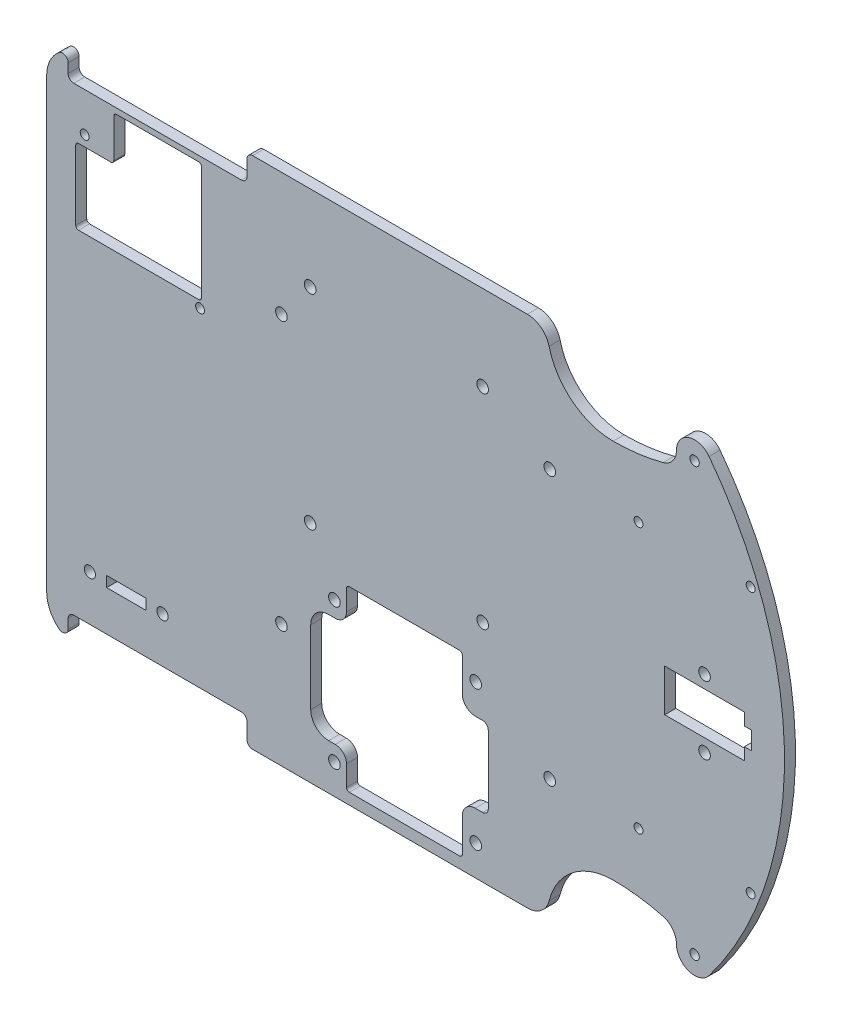
from build123d import *

# Parameters (mm, degrees)
CROQUIS1_W                = 209.55
CROQUIS1_H                = 146.05
SALIENTE_EXTRUIR1_DEPTH   = 3.1242
CROQUIS2_R                = 1.3335
CORTAR_EXTRUIR1_DEPTH     = 128.750584639
CROQUIS9_R                = 1.27
CORTAR_EXTRUIR6_DEPTH     = 128.750584639
CORTAR_EXTRUIR2_DEPTH     = 128.750584639
CROQUIS5_R                = 1.651
DRIVER_DEPTH              = 128.750584639
CROQUIS6_R                = 1.651
RASPI_DEPTH               = 128.750584639
CROQUIS8_R                = 1.27
DIFERENCIAL_TRASERO_DEPTH = 128.750584639
CROQUIS7_R                = 1.5875
CROQUIS7_W                = 11.1125
CROQUIS7_H                = 2.9972
CORTAR_EXTRUIR7_DEPTH     = 128.750584639
CROQUIS10_R               = 1.651
CROQUIS10_W               = 22.606
CROQUIS10_H               = 11.9888
CORTAR_EXTRUIR10_DEPTH    = 128.750584639
CORTAR_EXTRUIR11_DEPTH    = 128.750584639
CROQUIS12_R               = 1.651
CORTAR_EXTRUIR12_DEPTH    = 128.750584639


with BuildPart() as part:
    # Croquis1 → Saliente-Extruir1 (new body)
    with BuildSketch(Plane.XY):
        Rectangle(CROQUIS1_W, CROQUIS1_H)
    extrude(amount=SALIENTE_EXTRUIR1_DEPTH)

    # Croquis2 → Cortar-Extruir1 (cut, through all)
    with BuildSketch(Plane.XY.offset(3.1242)):
        with BuildLine():
            ThreePointArc((80.5799125, 60.7314), (79.928852882, 61.877042778), (78.6114125, 61.904002767))
            Line((78.6114125, 61.904002767), (78.6114125, 59.558797233))
            ThreePointArc((78.6114125, 59.558797233), (79.928852882, 59.585757222), (80.5799125, 60.7314))
        make_face()
        with BuildLine():
            Line((78.6114125, 59.558797233), (78.6114125, 61.904002767))
            ThreePointArc((78.6114125, 61.904002767), (77.9129125, 60.7314), (78.6114125, 59.558797233))
        make_face()
        with Locations(Location((79.2464125, -60.7314, 0), (0, 0, 180))):
            Circle(CROQUIS2_R)
    extrude(amount=-CORTAR_EXTRUIR1_DEPTH, mode=Mode.SUBTRACT)

    # Croquis9 → Cortar-Extruir6 (cut, through all)
    with BuildSketch(Plane.XY.offset(3.1242)):
        with Locations((63.3206125, 37.6809)):
            Circle(CROQUIS9_R)
        with Locations((95.1722125, 37.6809)):
            Circle(CROQUIS9_R)
        with Locations(Location((95.1722125, -37.6809, 0), (0, 0, 180))):
            Circle(CROQUIS9_R)
        with Locations(Location((63.3206125, -37.6809, 0), (0, 0, 180))):
            Circle(CROQUIS9_R)
    extrude(amount=-CORTAR_EXTRUIR6_DEPTH, mode=Mode.SUBTRACT)

    # Croquis3 → Cortar-Extruir2 (cut, through all)
    with BuildSketch(Plane.XY.offset(3.1242)):
        with BuildLine():
            Line((38.1, 67.507041999), (38.1, 73.025))
            Line((38.1, 73.025), (31.75, 73.025))
            ThreePointArc((31.75, 73.025), (35.663372801, 71.675801268), (37.913779422, 68.201539629))
            ThreePointArc((37.913779422, 68.201539629), (38.003556568, 67.853397075), (38.1, 67.507041999))
        make_face()
        with BuildLine():
            Line((74.0870375, 73.025), (38.1, 73.025))
            Line((38.1, 73.025), (38.1, 67.507041999))
            ThreePointArc((38.1, 67.507041999), (44.836488972, 57.735545708), (56.09351875, 53.975))
            ThreePointArc((56.09351875, 53.975), (63.258442282, 54.43812298), (70.304123502, 55.81978439))
            ThreePointArc((70.304123502, 55.81978439), (73.03168636, 57.631625564), (74.0870375, 60.7314))
            Line((74.0870375, 60.7314), (74.0870375, 73.025))
        make_face()
        with BuildLine():
            Line((104.775, 73.025), (74.0870375, 73.025))
            Line((74.0870375, 73.025), (74.0870375, 60.7314))
            ThreePointArc((74.0870375, 60.7314), (77.605786537, 65.622974066), (83.362384549, 63.842336271))
            ThreePointArc((83.362384549, 63.842336271), (99.279214777, 33.668769191), (104.775, 5.82e-07))
            Line((104.775, 5.82e-07), (104.775, 73.025))
        make_face()
        with BuildLine():
            Line((104.775, -73.025), (104.775, 5.82e-07))
            ThreePointArc((104.775, 5.82e-07), (99.279214962, -33.668768639), (83.362384549, -63.842336271))
            ThreePointArc((83.362384549, -63.842336271), (77.605786537, -65.622974066), (74.0870375, -60.7314))
            Line((74.0870375, -60.7314), (74.0870375, -73.025))
            Line((74.0870375, -73.025), (104.775, -73.025))
        make_face()
        with BuildLine():
            Line((74.0870375, -73.025), (74.0870375, -60.7314))
            ThreePointArc((74.0870375, -60.7314), (73.03168636, -57.631625564), (70.304123502, -55.81978439))
            ThreePointArc((70.304123502, -55.81978439), (63.258442282, -54.43812298), (56.09351875, -53.975))
            ThreePointArc((56.09351875, -53.975), (44.836488972, -57.735545708), (38.1, -67.507041999))
            Line((38.1, -67.507041999), (38.1, -73.025))
            Line((38.1, -73.025), (74.0870375, -73.025))
        make_face()
        with BuildLine():
            ThreePointArc((37.913779422, -68.201539629), (35.663372801, -71.675801268), (31.75, -73.025))
            Line((31.75, -73.025), (38.1, -73.025))
            Line((38.1, -73.025), (38.1, -67.507041999))
            ThreePointArc((38.1, -67.507041999), (38.003556568, -67.853397075), (37.913779422, -68.201539629))
        make_face()
        with BuildLine():
            ThreePointArc((-104.775, 63.5), (-101.985192091, 70.235192091), (-95.25, 73.025))
            Line((-95.25, 73.025), (-104.775, 73.025))
            Line((-104.775, 73.025), (-104.775, 63.5))
        make_face()
        with BuildLine():
            Line((-104.775, -73.025), (-95.25, -73.025))
            ThreePointArc((-95.25, -73.025), (-101.985192091, -70.235192091), (-104.775, -63.5))
            Line((-104.775, -63.5), (-104.775, -73.025))
        make_face()
    extrude(amount=-CORTAR_EXTRUIR2_DEPTH, mode=Mode.SUBTRACT)

    # Croquis5 → Driver (cut, through all)
    with BuildSketch(Plane.XY.offset(3.1242)):
        with BuildLine():
            Line((12.47775, -19.2786), (-18.82775, -19.2786))
            ThreePointArc((-18.82775, -19.2786), (-19.389016008, -19.511083992), (-19.6215, -20.07235))
            Line((-19.6215, -20.07235), (-19.6215, -25.8826))
            ThreePointArc((-19.6215, -25.8826), (-20.55143597, -28.12766403), (-22.7965, -29.0576))
            Line((-22.7965, -29.0576), (-24.7015, -29.0576))
            ThreePointArc((-24.7015, -29.0576), (-28.293602448, -30.545497552), (-29.7815, -34.1376))
            Line((-29.7815, -34.1376), (-29.7815, -54.991))
            ThreePointArc((-29.7815, -54.991), (-28.293602448, -58.583102448), (-24.7015, -60.071))
            Line((-24.7015, -60.071), (-22.7965, -60.071))
            ThreePointArc((-22.7965, -60.071), (-20.55143597, -61.00093597), (-19.6215, -63.246))
            Line((-19.6215, -63.246), (-19.6215, -69.05625))
            ThreePointArc((-19.6215, -69.05625), (-19.389016008, -69.617516008), (-18.82775, -69.85))
            Line((-18.82775, -69.85), (12.47775, -69.85))
            ThreePointArc((12.47775, -69.85), (13.039016008, -69.617516008), (13.2715, -69.05625))
            Line((13.2715, -69.05625), (13.2715, -59.563))
            ThreePointArc((13.2715, -59.563), (14.350225725, -56.958725725), (16.9545, -55.88))
            Line((16.9545, -55.88), (19.05, -55.88))
            ThreePointArc((19.05, -55.88), (20.172532015, -55.415032015), (20.6375, -54.2925))
            Line((20.6375, -54.2925), (20.6375, -34.8361))
            ThreePointArc((20.6375, -34.8361), (20.172532015, -33.713567985), (19.05, -33.2486))
            Line((19.05, -33.2486), (16.9545, -33.2486))
            ThreePointArc((16.9545, -33.2486), (14.350225725, -32.169874275), (13.2715, -29.5656))
            Line((13.2715, -29.5656), (13.2715, -20.07235))
            ThreePointArc((13.2715, -20.07235), (13.039016008, -19.511083992), (12.47775, -19.2786))
        make_face()
        with Locations((17.0815, -24.7396)):
            Circle(CROQUIS5_R)
        with Locations((-23.0505, -24.6126)):
            Circle(CROQUIS5_R)
        with Locations(Location((17.0815, -64.389, 0), (0, 0, 180))):
            Circle(CROQUIS5_R)
        with Locations(Location((-23.0505, -64.516, 0), (0, 0, 180))):
            Circle(CROQUIS5_R)
    extrude(amount=-DRIVER_DEPTH, mode=Mode.SUBTRACT)

    # Croquis6 → RasPi (cut, through all)
    with BuildSketch(Plane.XY.offset(3.1242)):
        with Locations((-29.95, 48.8814)):
            Circle(CROQUIS6_R)
        with Locations((19.05, 48.8814)):
            Circle(CROQUIS6_R)
        with Locations((19.05, -9.1186)):
            Circle(CROQUIS6_R)
        with Locations((-29.95, -9.1186)):
            Circle(CROQUIS6_R)
    extrude(amount=-RASPI_DEPTH, mode=Mode.SUBTRACT)

    # Croquis8 → Diferencial trasero (cut, through all)
    with BuildSketch(Plane.XY.offset(3.1242)):
        with Locations((-93.98, 54.3306)):
            Circle(CROQUIS8_R)
        with Locations((-61.214, 28.0162)):
            Circle(CROQUIS8_R)
    extrude(amount=-DIFERENCIAL_TRASERO_DEPTH, mode=Mode.SUBTRACT)

    # Croquis7 → Cortar-Extruir7 (cut, through all)
    with BuildSketch(Plane.XY.offset(3.1242)):
        with Locations((-92.508859415, -52.4764)):
            Circle(CROQUIS7_R)
        with Locations((-71.871359415, -52.4764)):
            Circle(CROQUIS7_R)
        with Locations((-82.190109415, -52.4764)):
            Rectangle(CROQUIS7_W, CROQUIS7_H)
    extrude(amount=-CORTAR_EXTRUIR7_DEPTH, mode=Mode.SUBTRACT)

    # Croquis10 → Cortar-Extruir10 (cut, through all)
    with BuildSketch(Plane.XY.offset(3.1242)):
        with Locations((82.0674, 9.652)):
            Circle(CROQUIS10_R)
        with Locations((82.0674, 0)):
            Rectangle(CROQUIS10_W, CROQUIS10_H)
        with Locations((82.0674, -9.652)):
            Circle(CROQUIS10_R)
        Polygon((93.3704, -1.966579717), (93.3704, -2.54), (95.4024, -2.54), (95.4024, 2.54), (93.3704, 2.54), align=None)
    extrude(amount=-CORTAR_EXTRUIR10_DEPTH, mode=Mode.SUBTRACT)

    # Croquis11 → Cortar-Extruir11 (cut, through all)
    with BuildSketch(Plane.XY.offset(3.1242)):
        with BuildLine():
            Line((-61.62675, 63.8302), (-84.93125, 63.8302))
            ThreePointArc((-84.93125, 63.8302), (-85.492516008, 63.597716008), (-85.725, 63.03645))
            Line((-85.725, 63.03645), (-85.725, 52.0827))
            ThreePointArc((-85.725, 52.0827), (-85.957483992, 51.521433992), (-86.51875, 51.28895))
            Line((-86.51875, 51.28895), (-95.72625, 51.28895))
            ThreePointArc((-95.72625, 51.28895), (-96.287516008, 51.056466008), (-96.52, 50.4952))
            Line((-96.52, 50.4952), (-96.52, 30.7467))
            ThreePointArc((-96.52, 30.7467), (-96.287516008, 30.185433992), (-95.72625, 29.95295))
            Line((-95.72625, 29.95295), (-61.62675, 29.95295))
            ThreePointArc((-61.62675, 29.95295), (-61.065483992, 30.185433992), (-60.833, 30.7467))
            Line((-60.833, 30.7467), (-60.833, 63.03645))
            ThreePointArc((-60.833, 63.03645), (-61.065483992, 63.597716008), (-61.62675, 63.8302))
        make_face()
        with BuildLine():
            ThreePointArc((-95.25, 73.025), (-98.445006556, 72.473157644), (-101.2698, 70.881573881))
            ThreePointArc((-101.2698, 70.881573881), (-99.585538364, 71.085343471), (-98.679, 69.651311567))
            Line((-98.679, 69.651311567), (-98.679, 67.0052))
            ThreePointArc((-98.679, 67.0052), (-98.214032015, 65.882667985), (-97.0915, 65.4177))
            Line((-97.0915, 65.4177), (-49.4665, 65.4177))
            ThreePointArc((-49.4665, 65.4177), (-48.343967985, 65.882667985), (-47.879, 67.0052))
            Line((-47.879, 67.0052), (-47.879, 71.4375))
            ThreePointArc((-47.879, 71.4375), (-47.414032015, 72.560032015), (-46.2915, 73.025))
            Line((-46.2915, 73.025), (-95.25, 73.025))
        make_face()
        with BuildLine():
            ThreePointArc((-98.679, -69.651311567), (-99.585538364, -71.085343471), (-101.2698, -70.881573881))
            ThreePointArc((-101.2698, -70.881573881), (-98.445006556, -72.473157644), (-95.25, -73.025))
            Line((-95.25, -73.025), (-46.2915, -73.025))
            ThreePointArc((-46.2915, -73.025), (-47.414032015, -72.560032015), (-47.879, -71.4375))
            Line((-47.879, -71.4375), (-47.879, -67.0052))
            ThreePointArc((-47.879, -67.0052), (-48.343967985, -65.882667985), (-49.4665, -65.4177))
            Line((-49.4665, -65.4177), (-97.0915, -65.4177))
            ThreePointArc((-97.0915, -65.4177), (-98.214032015, -65.882667985), (-98.679, -67.0052))
            Line((-98.679, -67.0052), (-98.679, -69.651311567))
        make_face()
    extrude(amount=-CORTAR_EXTRUIR11_DEPTH, mode=Mode.SUBTRACT)

    # Croquis12 → Cortar-Extruir12 (cut, through all)
    with BuildSketch(Plane.XY.offset(3.1242)):
        with Locations((38.1, 38.1)):
            Circle(CROQUIS12_R)
        with Locations((-38.1, 38.1)):
            Circle(CROQUIS12_R)
        with Locations((-38.1, -38.1)):
            Circle(CROQUIS12_R)
        with Locations((38.1, -38.1)):
            Circle(CROQUIS12_R)
    extrude(amount=-CORTAR_EXTRUIR12_DEPTH, mode=Mode.SUBTRACT)


solid = part.part
